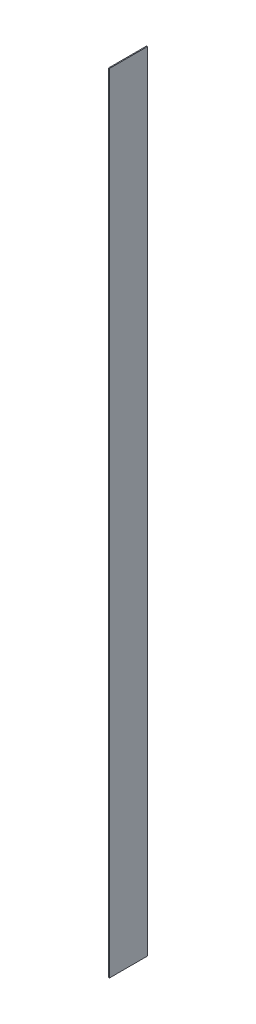
from build123d import *

# Parameters (mm, degrees)
SKETCH1_W           = 50.8
SKETCH1_H           = 1054.1
BOSS_EXTRUDE1_DEPTH = 1.27


with BuildPart() as part:
    # Sketch1 → Boss-Extrude1 (new body)
    with BuildSketch(Plane(origin=(0, 0, 0), x_dir=(0, 0, -1), z_dir=(1, 0, 0))):
        with Locations((0, 527.05)):
            Rectangle(SKETCH1_W, SKETCH1_H)
    extrude(amount=BOSS_EXTRUDE1_DEPTH)


solid = part.part
